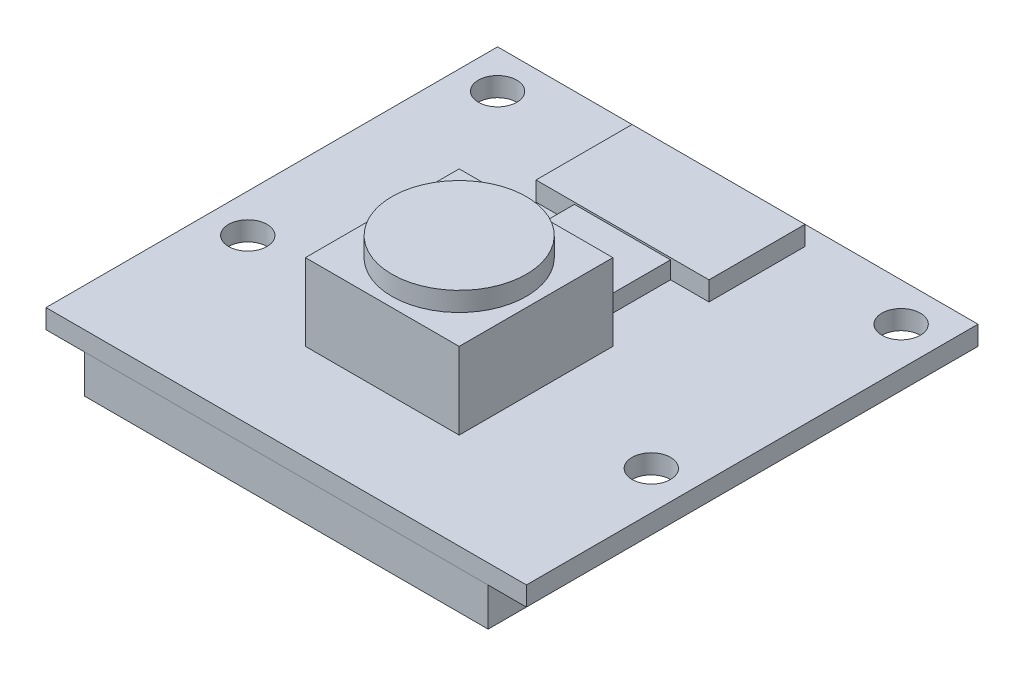
from build123d import *

# Parameters (mm, degrees)
SKETCH1_W           = 25
SKETCH1_H           = 23.5
BOSS_EXTRUDE1_DEPTH = 1
SKETCH2_R           = 1
CUT_EXTRUDE1_DEPTH  = 1
SKETCH3_W           = 9
SKETCH3_H           = 5
BOSS_EXTRUDE2_DEPTH = 1
SKETCH4_W           = 5
SKETCH4_H           = 4.5
BOSS_EXTRUDE3_DEPTH = 0.9
SKETCH5_W           = 8
SKETCH5_H           = 8
BOSS_EXTRUDE4_DEPTH = 4
SKETCH6_R           = 3.5
BOSS_EXTRUDE5_DEPTH = 1
SKETCH8_W           = 21
SKETCH8_H           = 5
BOSS_EXTRUDE6_DEPTH = 2


with BuildPart() as part:
    # Sketch1 → Boss-Extrude1 (new body)
    with BuildSketch(Plane(origin=(0, 0, 0), x_dir=(1, 0, 0), z_dir=(0, 1, 0))):
        Rectangle(SKETCH1_W, SKETCH1_H)
    extrude(amount=BOSS_EXTRUDE1_DEPTH)

    # Sketch2 → Cut-Extrude1 (cut)
    with BuildSketch(Plane(origin=(0, 1, 0), x_dir=(1, 0, 0), z_dir=(0, 1, 0))):
        with Locations((-10.5, 9.75)):
            Circle(SKETCH2_R)
        with Locations((10.5, 9.75)):
            Circle(SKETCH2_R)
        with Locations((10.5, -3.25)):
            Circle(SKETCH2_R)
        with Locations((-10.5, -3.25)):
            Circle(SKETCH2_R)
    extrude(amount=-CUT_EXTRUDE1_DEPTH, mode=Mode.SUBTRACT)

    # Sketch3 → Boss-Extrude2 (add)
    with BuildSketch(Plane(origin=(0, 1, 0), x_dir=(1, 0, 0), z_dir=(0, 1, 0))):
        with Locations((0, 8.25)):
            Rectangle(SKETCH3_W, SKETCH3_H)
    extrude(amount=BOSS_EXTRUDE2_DEPTH)

    # Sketch4 → Boss-Extrude3 (add)
    with BuildSketch(Plane(origin=(0, 1, 0), x_dir=(1, 0, 0), z_dir=(0, 1, 0))):
        with Locations((0, 3.5)):
            Rectangle(SKETCH4_W, SKETCH4_H)
    extrude(amount=BOSS_EXTRUDE3_DEPTH)

    # Sketch5 → Boss-Extrude4 (add)
    with BuildSketch(Plane(origin=(0, 1, 0), x_dir=(1, 0, 0), z_dir=(0, 1, 0))):
        with Locations((0, -2.75)):
            Rectangle(SKETCH5_W, SKETCH5_H)
    extrude(amount=BOSS_EXTRUDE4_DEPTH)

    # Sketch6 → Boss-Extrude5 (add)
    with BuildSketch(Plane(origin=(0, 5, 0), x_dir=(1, 0, 0), z_dir=(0, 1, 0))):
        with Locations((0, -2.75)):
            Circle(SKETCH6_R)
    extrude(amount=BOSS_EXTRUDE5_DEPTH)

    # Sketch8 → Boss-Extrude6 (add)
    with BuildSketch(Plane.XZ):
        with Locations((0, 9.24)):
            Rectangle(SKETCH8_W, SKETCH8_H)
    extrude(amount=BOSS_EXTRUDE6_DEPTH)


solid = part.part
